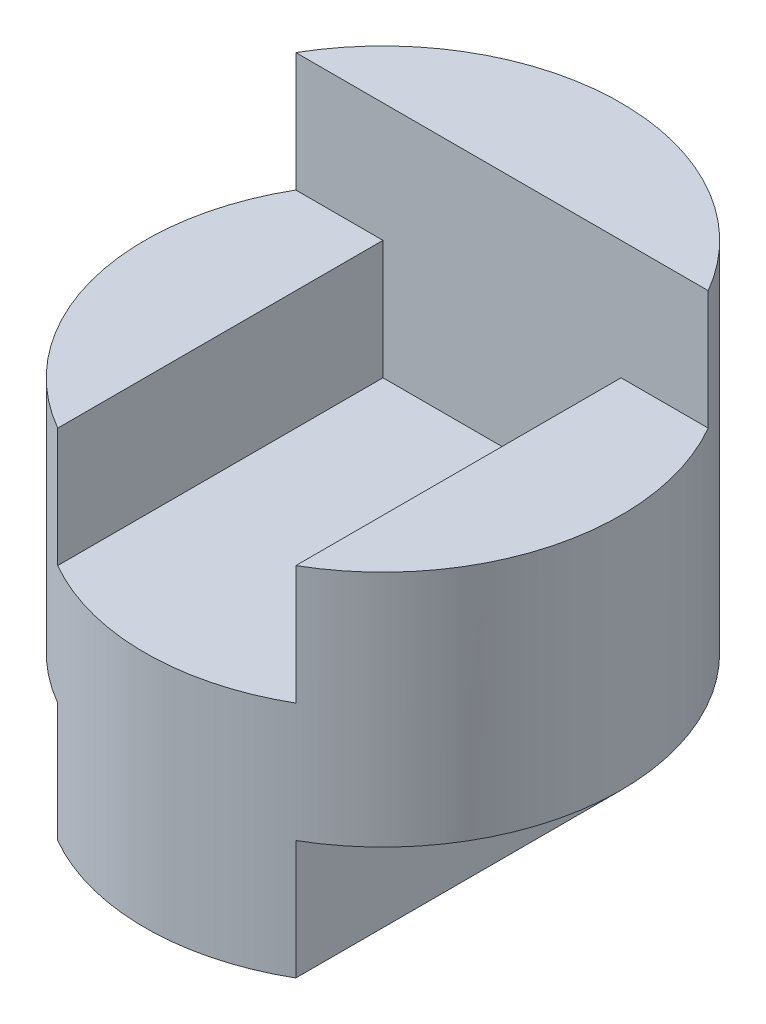
from build123d import *

# Parameters (mm, degrees)
SKETCH1_R               = 2
BOSS_EXTRUDE1_DEPTH     = 4
SKETCH2_W               = 1
SKETCH2_H               = 1
CUT_EXTRUDE1_DEPTH      = 2
CUT_EXTRUDE2_DEPTH      = 4
CUT_EXTRUDE2_DEPTH_BACK = 1
SKETCH4_W               = 1
SKETCH4_H               = 1
CUT_EXTRUDE3_DEPTH      = 5


with BuildPart() as part:
    # Sketch1 → Boss-Extrude1 (new body)
    with BuildSketch(Plane(origin=(0, 0, 0), x_dir=(1, 0, 0), z_dir=(0, 1, 0))):
        Circle(SKETCH1_R)
    extrude(amount=BOSS_EXTRUDE1_DEPTH)

    # Sketch2 → Cut-Extrude1 (cut, symmetric)
    with BuildSketch(Plane.XY):
        with Locations((-1.5, 0.5)):
            Rectangle(SKETCH2_W, SKETCH2_H)
        with Locations((1.5, 0.5)):
            Rectangle(SKETCH2_W, SKETCH2_H)
    extrude(amount=CUT_EXTRUDE1_DEPTH, both=True, mode=Mode.SUBTRACT)

    # Sketch3 → Cut-Extrude2 (cut, two sides)
    with BuildSketch(Plane.XY) as cut_extrude2_sk:
        Polygon((-2, 4), (2, 4), (2, 3), (1, 3), (1, 2), (-1, 2), (-1, 3), (-2, 3), align=None)
    extrude(amount=CUT_EXTRUDE2_DEPTH, mode=Mode.SUBTRACT)
    extrude(cut_extrude2_sk.sketch, amount=-CUT_EXTRUDE2_DEPTH_BACK, mode=Mode.SUBTRACT)

    # Sketch4 → Cut-Extrude3 (cut, symmetric)
    with BuildSketch(Plane(origin=(0, 0, 0), x_dir=(0, 0, -1), z_dir=(1, 0, 0))):
        with Locations((1.5, 0.5)):
            Rectangle(SKETCH4_W, SKETCH4_H)
    extrude(amount=CUT_EXTRUDE3_DEPTH, both=True, mode=Mode.SUBTRACT)


solid = part.part
